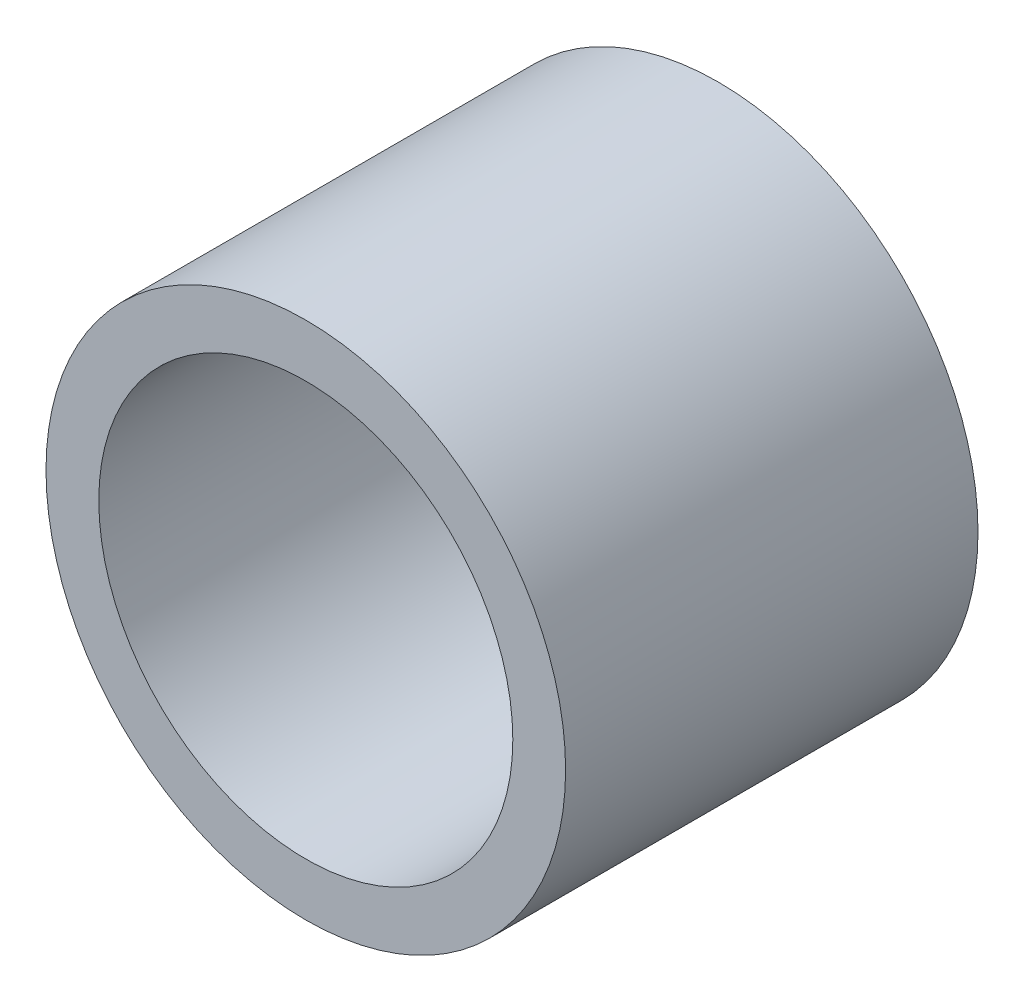
from build123d import *

# Parameters (mm, degrees)
SKETCH1_R           = 4.0005
SKETCH1_R_2         = 3.1877
BOSS_EXTRUDE1_DEPTH = 3.175


with BuildPart() as part:
    # Sketch1 → Boss-Extrude1 (new body, symmetric)
    with BuildSketch(Plane.XY):
        Circle(SKETCH1_R)
        Circle(SKETCH1_R_2, mode=Mode.SUBTRACT)
    extrude(amount=BOSS_EXTRUDE1_DEPTH, both=True)


solid = part.part
